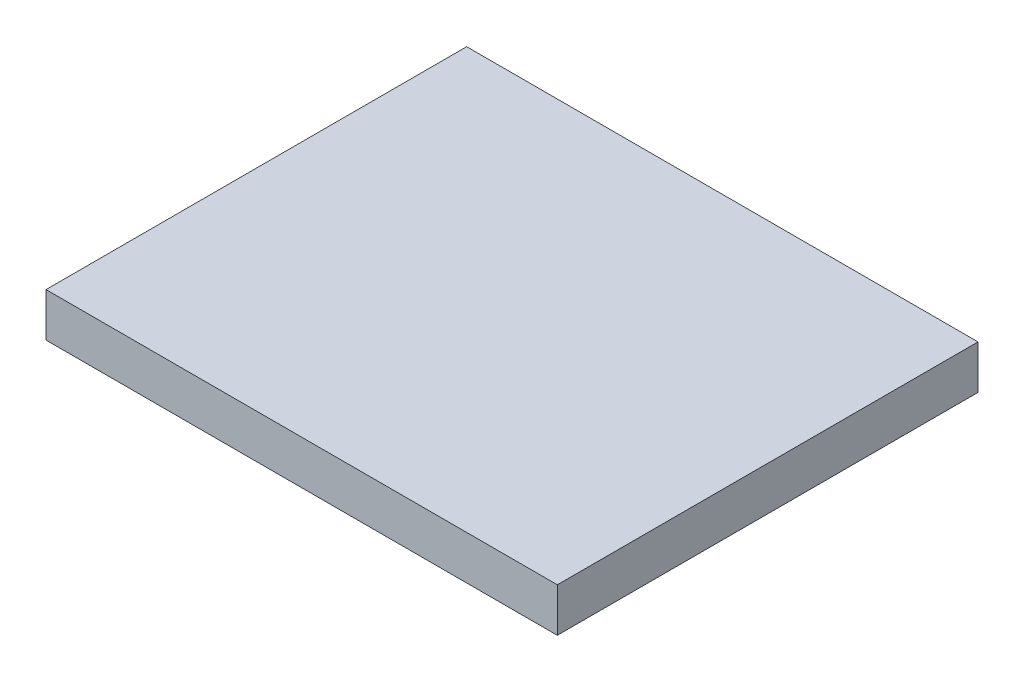
from build123d import *

# Parameters (mm, degrees)
SKETCH1_W           = 116.828625277
SKETCH1_H           = 96.120042649
BOSS_EXTRUDE1_DEPTH = 10


with BuildPart() as part:
    # Sketch1 → Boss-Extrude1 (new body)
    with BuildSketch(Plane(origin=(0, 0, 0), x_dir=(1, 0, 0), z_dir=(0, 1, 0))):
        with Locations((7.223556452, -21.257441048)):
            Rectangle(SKETCH1_W, SKETCH1_H)
    extrude(amount=BOSS_EXTRUDE1_DEPTH)


solid = part.part
